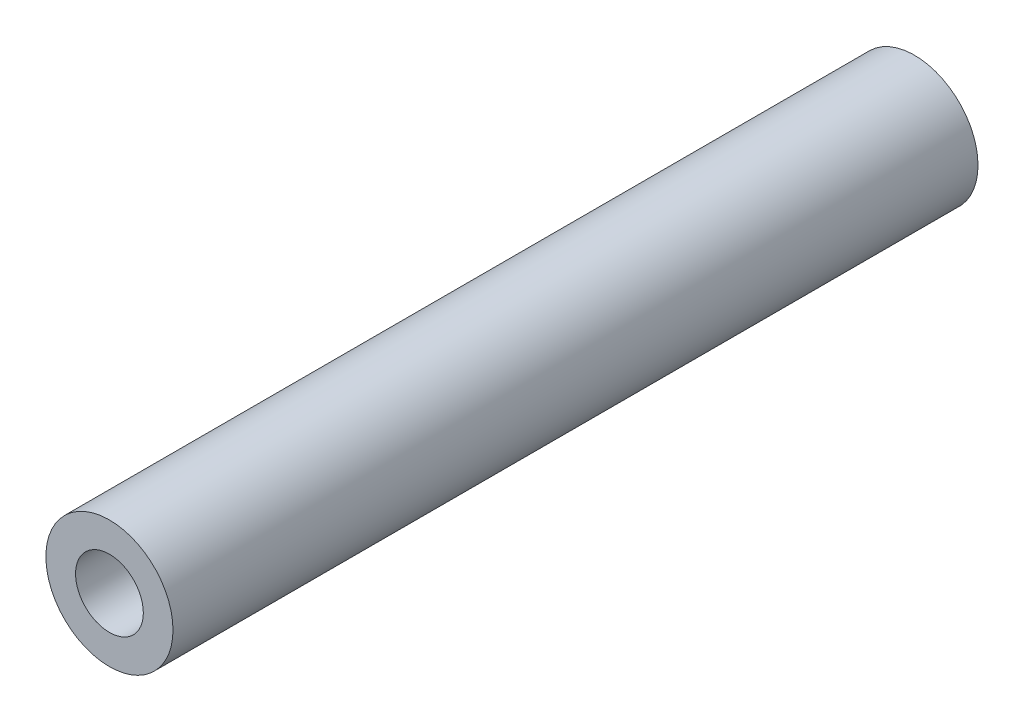
from build123d import *

# Parameters (mm, degrees)
SKETCH1_R           = 3
BOSS_EXTRUDE1_DEPTH = 19
M3_CLEARANCE_HOLE_D = 3.2


with BuildPart() as part:
    # Sketch1 → Boss-Extrude1 (new, symmetric)
    with BuildSketch(Plane.XY):
        Circle(SKETCH1_R)
    extrude(amount=BOSS_EXTRUDE1_DEPTH, both=True)

    # M3 Clearance Hole (through all)
    with Locations(Plane.XY.offset(19)):
        with Locations((0, 0)):
            Hole(M3_CLEARANCE_HOLE_D / 2)


solid = part.part
